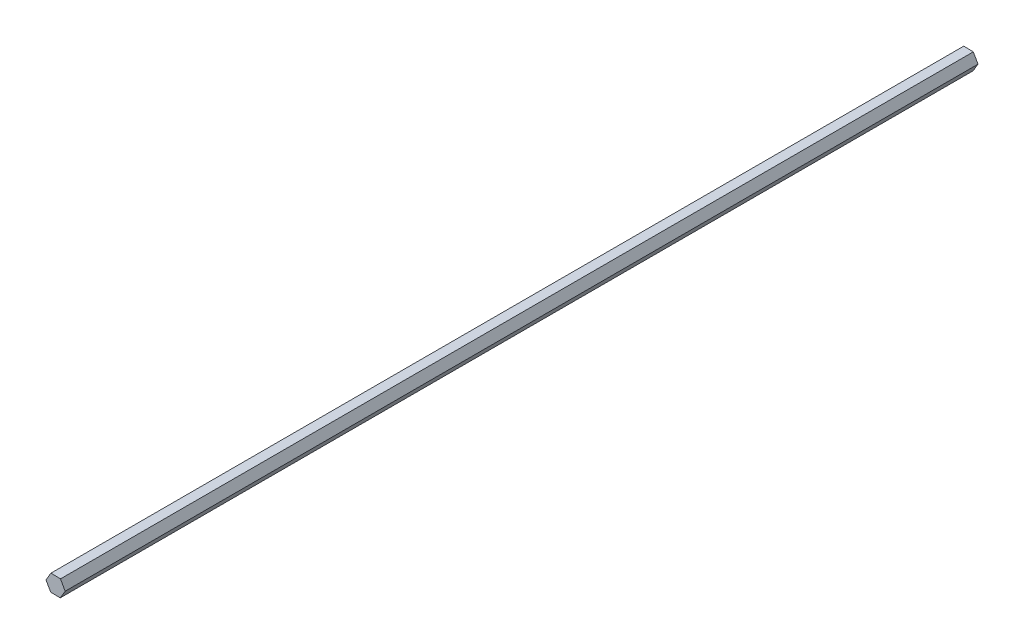
from build123d import *

# Parameters (mm, degrees)
BOSS_EXTRUDE1_DEPTH = 698.5


with BuildPart() as part:
    # Sketch1 → Boss-Extrude1 (new body)
    with BuildSketch(Plane.XY):
        Polygon((3.573216858, -6.402769293), (7.331569291, -0.106888075), (3.758352434, 6.295881219), (-3.573216858, 6.402769293), (-7.331569291, 0.106888075), (-3.758352434, -6.295881219), align=None)
    extrude(amount=BOSS_EXTRUDE1_DEPTH)


solid = part.part
